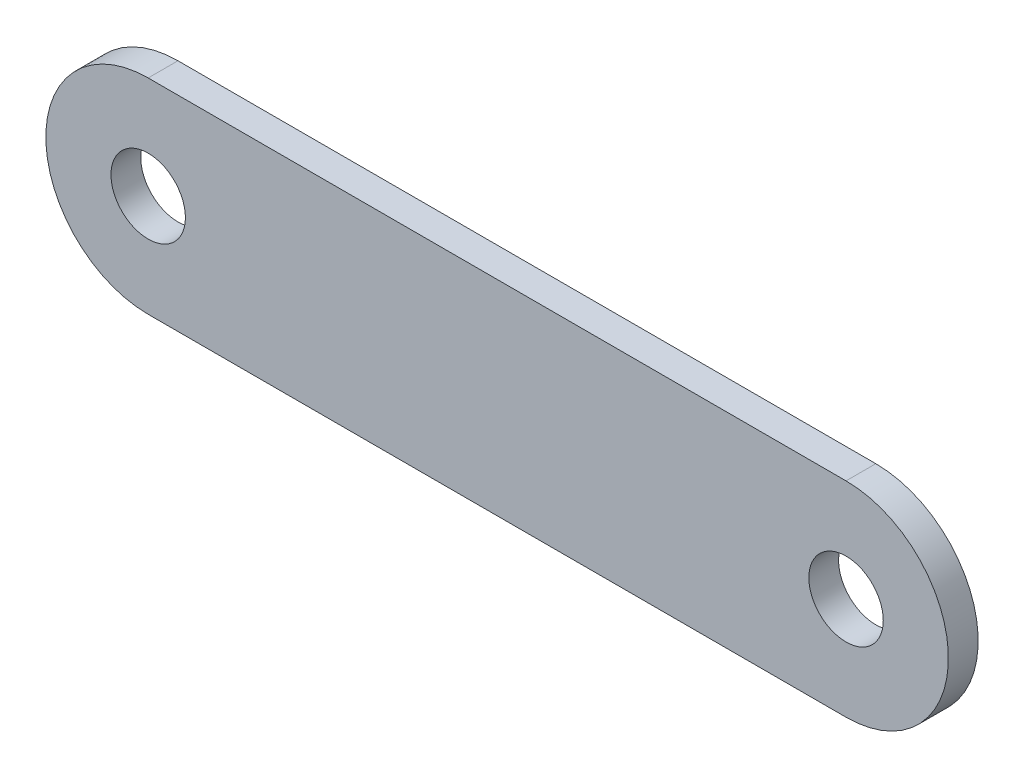
from build123d import *

# Parameters (mm, degrees)
SKETCH1_R           = 4
BOSS_EXTRUDE1_DEPTH = 3.2


with BuildPart() as part:
    # Sketch1 → Boss-Extrude1 (new body)
    with BuildSketch(Plane.XY):
        with BuildLine():
            Line((0, 11), (75, 11))
            ThreePointArc((75, 11), (86, 0), (75, -11))
            Line((75, -11), (0, -11))
            ThreePointArc((0, -11), (-11, 0), (0, 11))
        make_face()
        Circle(SKETCH1_R, mode=Mode.SUBTRACT)
        with Locations((75, 0)):
            Circle(SKETCH1_R, mode=Mode.SUBTRACT)
    extrude(amount=BOSS_EXTRUDE1_DEPTH)


solid = part.part
